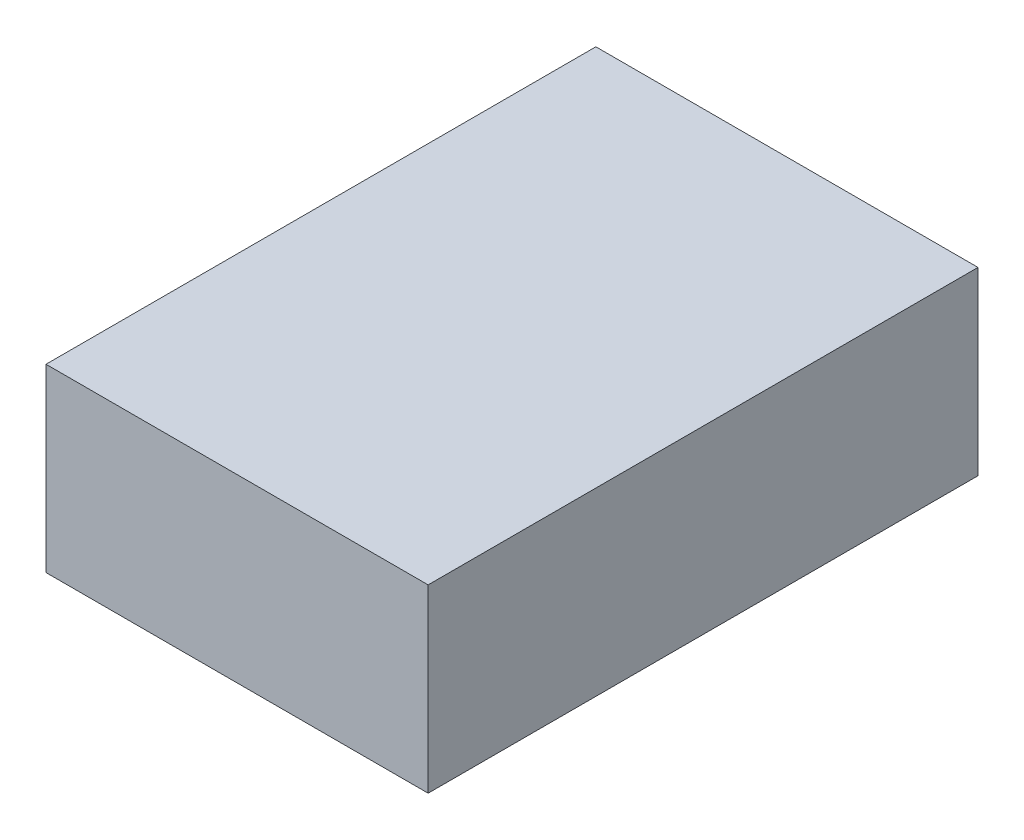
from build123d import *

# Parameters (mm, degrees)
SKETCH1_W                = 101.22262421
SKETCH1_H                = 47.794776075
BOSS_EXTRUDE1_DEPTH      = 140.649714648
BOSS_EXTRUDE1_DEPTH_BACK = 5


with BuildPart() as part:
    # Sketch1 → Boss-Extrude1 (new body, two sides)
    with BuildSketch(Plane.XY) as boss_extrude1_sk:
        with Locations((14.876601181, 175.521421618)):
            Rectangle(SKETCH1_W, SKETCH1_H)
    extrude(amount=BOSS_EXTRUDE1_DEPTH)
    extrude(boss_extrude1_sk.sketch, amount=-BOSS_EXTRUDE1_DEPTH_BACK)


solid = part.part
